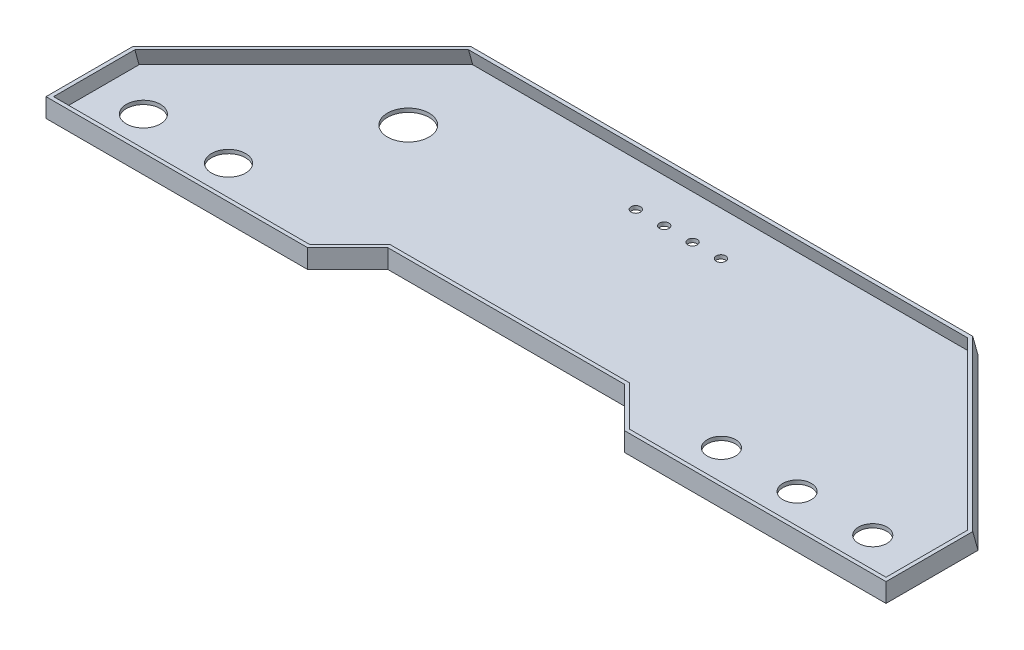
from build123d import *

# Parameters (mm, degrees)
SHELL1_T           = -2
SKETCH4_R          = 2.5
SKETCH4_R_2        = 7.5
SKETCH4_R_3        = 9
SKETCH4_R_4        = 11
CUT_EXTRUDE1_DEPTH = 10


with BuildPart() as part:
    # Sketch1 → Loft2 section 0
    with BuildSketch(Plane(origin=(0, 0, 0), x_dir=(1, 0, 0), z_dir=(0, 1, 0))):
        Polygon((-132.627416996, -6), (132.627416996, -6), (221.999999995, -95.372582999), (221.999999995, -144), (83.69848481, -144), (62.485281374, -122.786796564), (-62.485281374, -122.786796564), (-83.69848481, -144), (-221.999999995, -144), (-221.999999995, -95.372582999), align=None)
    # Sketch2 → Loft2 section 1
    with BuildSketch(Plane(origin=(0, 10, 0), x_dir=(1, 0, 0), z_dir=(0, 1, 0))):
        Polygon((-83.698484794, -144), (-62.485281361, -122.786796562), (62.485281387, -122.786796547), (83.69848481, -143.999999995), (222.00000001, -143.999999995), (222.00000001, -98.149280245), (132.627417005, -8.77669724), (-132.627416995, -8.77669724), (-221.999999995, -98.14928025), (-221.999999995, -144), align=None)
    loft()

    # Shell1
    shell1_openings = [part.faces().sort_by_distance(p)[0] for p in [
        (8e-09, 10, 103.542554807),
    ]]
    offset(amount=SHELL1_T, openings=shell1_openings, kind=Kind.INTERSECTION)

    # Sketch4 → Cut-Extrude1 (cut)
    with BuildSketch(Plane.XZ):
        with Locations((22.5, 31.74)):
            Circle(SKETCH4_R)
        with Locations((7.5, 31.74)):
            Circle(SKETCH4_R)
        with Locations((-7.5, 31.74)):
            Circle(SKETCH4_R)
        with Locations((-22.5, 31.74)):
            Circle(SKETCH4_R)
        with Locations((189.259999995, 118.26)):
            Circle(SKETCH4_R_2)
        with Locations((149.259999995, 118.26)):
            Circle(SKETCH4_R_2)
        with Locations((109.259999995, 118.26)):
            Circle(SKETCH4_R_2)
        with Locations((-151.259999995, 118.26)):
            Circle(SKETCH4_R_3)
        with Locations((-196.259999995, 118.26)):
            Circle(SKETCH4_R_3)
        with Locations((-121.259999995, 53.26)):
            Circle(SKETCH4_R_4)
    extrude(amount=-CUT_EXTRUDE1_DEPTH, mode=Mode.SUBTRACT)


solid = part.part
